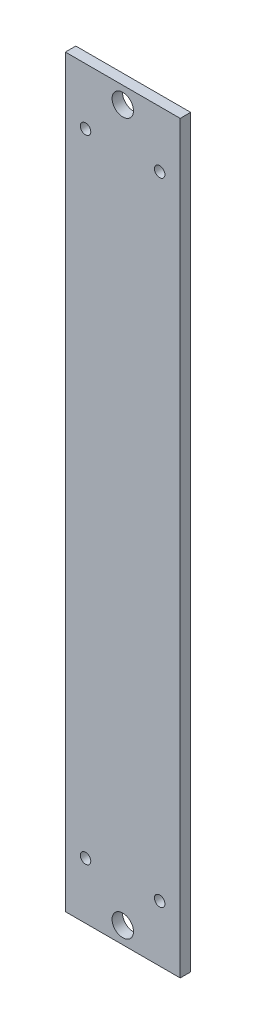
from build123d import *

# Parameters (mm, degrees)
SKETCH1_W           = 34.1
SKETCH1_H           = 221
SKETCH1_R           = 3.175
SKETCH1_R_2         = 1.55
BOSS_EXTRUDE1_DEPTH = 3.1


with BuildPart() as part:
    # Sketch1 → Boss-Extrude1 (new body)
    with BuildSketch(Plane.XY):
        with Locations((17.05, 110.5)):
            Rectangle(SKETCH1_W, SKETCH1_H)
        with Locations((17.05, 216)):
            Circle(SKETCH1_R, mode=Mode.SUBTRACT)
        with Locations((17.05, 5)):
            Circle(SKETCH1_R, mode=Mode.SUBTRACT)
        with Locations((6, 204.25)):
            Circle(SKETCH1_R_2, mode=Mode.SUBTRACT)
        with Locations((28, 204.25)):
            Circle(SKETCH1_R_2, mode=Mode.SUBTRACT)
        with Locations((28, 16.75)):
            Circle(SKETCH1_R_2, mode=Mode.SUBTRACT)
        with Locations((6, 16.75)):
            Circle(SKETCH1_R_2, mode=Mode.SUBTRACT)
    extrude(amount=BOSS_EXTRUDE1_DEPTH)


solid = part.part
